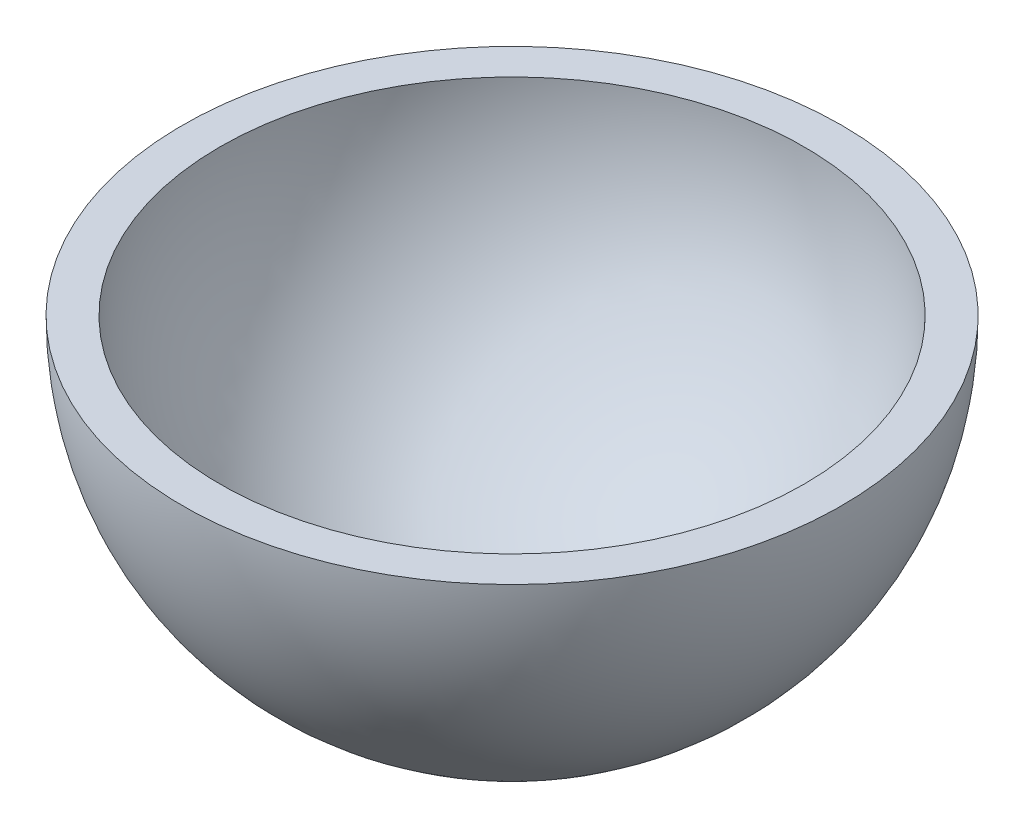
from build123d import *

# Parameters (mm, degrees)
REVOLVE1_ANGLE = 180
SHELL1_T       = -1.25


with BuildPart() as part:
    # Sketch1 → Revolve1 (revolve)
    with BuildSketch(Plane(origin=(0, 0, 0), x_dir=(1, 0, 0), z_dir=(0, 1, 0))):
        with BuildLine():
            Line((0, 0), (0, 22))
            ThreePointArc((0, 22), (11, 11), (0, 0))
        make_face()
    revolve(axis=Axis((0, 0, 0), (0, 0, -1)), revolution_arc=REVOLVE1_ANGLE)

    # Shell1
    shell1_openings = [part.faces().sort_by_distance(p)[0] for p in [
        (0, 0, -11),
    ]]
    offset(amount=SHELL1_T, openings=shell1_openings)


solid = part.part
